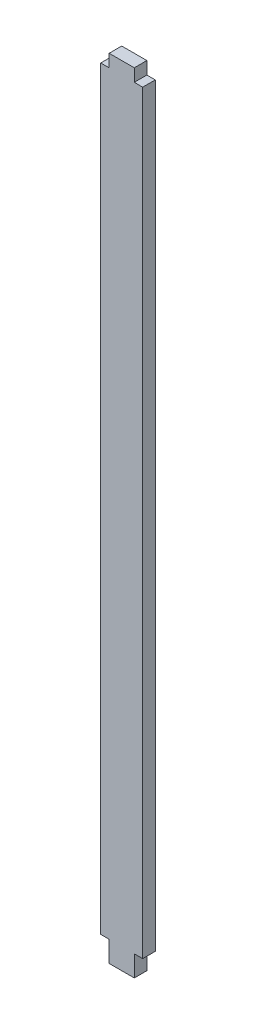
from build123d import *

# Parameters (mm, degrees)
RESSALTO_EXTRUS_O1_DEPTH = 3


with BuildPart() as part:
    # Esboço1 → Ressalto-extrusão1 (new body)
    with BuildSketch(Plane.XY):
        Polygon((-3, 90), (-5, 90), (-5, -90), (-3, -90), (-3, -95), (3, -95), (3, -90), (5, -90), (5, 90), (3, 90), (3, 93), (-3, 93), align=None)
    extrude(amount=RESSALTO_EXTRUS_O1_DEPTH)


solid = part.part
